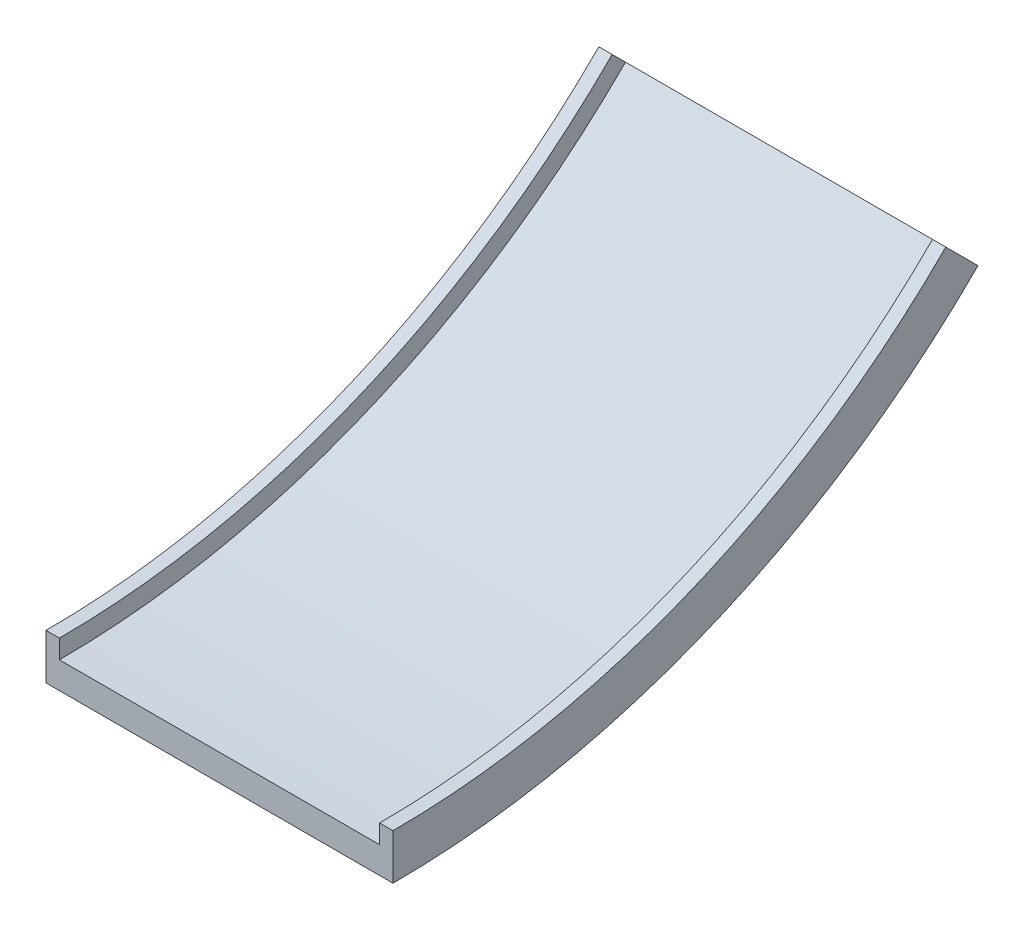
from build123d import *

# Parameters (mm, degrees)
REVOLVE1_ANGLE = 45


with BuildPart() as part:
    # Sketch1 → Revolve1 (revolve)
    with BuildSketch(Plane.XY):
        Polygon((0, -85.236081748), (0, 0), (25, 0), (25, -35.236081748), (625, -35.236081748), (625, 0), (650, 0), (650, -85.236081748), align=None)
    revolve(axis=Axis((0, 1464.763918252, 0), (1, 0, 0)), revolution_arc=REVOLVE1_ANGLE)


solid = part.part
